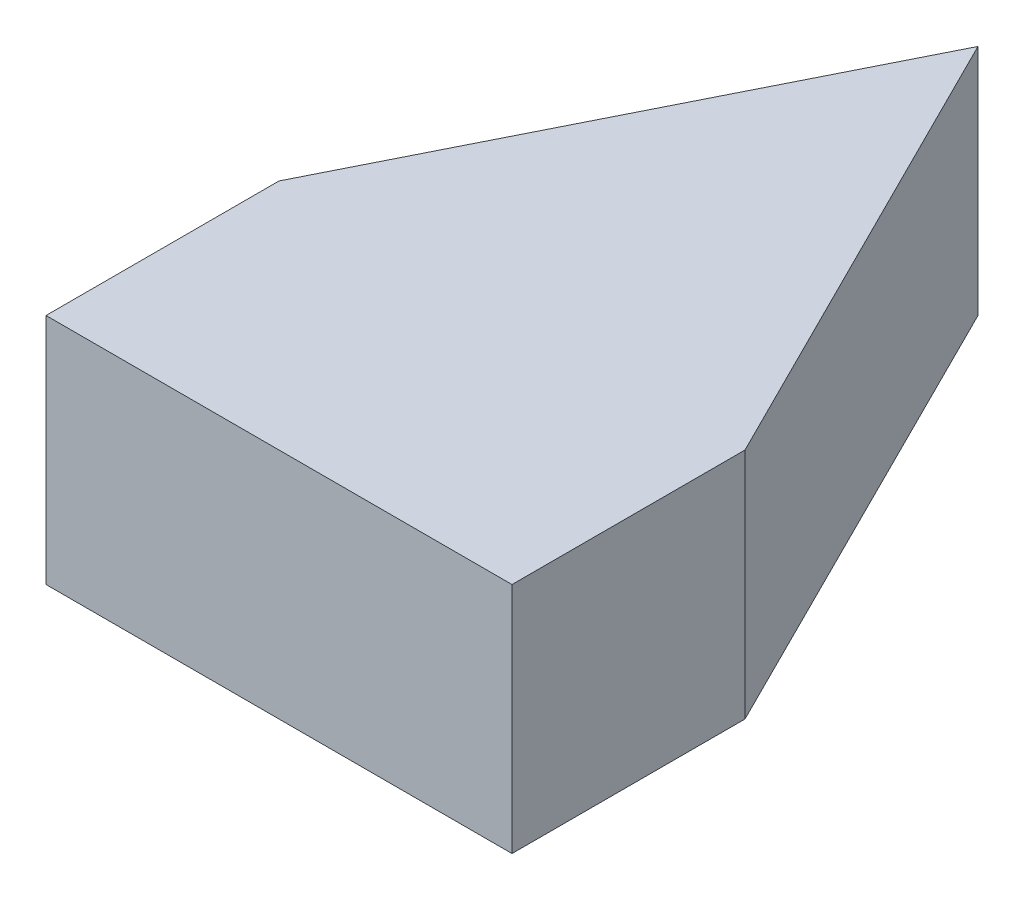
from build123d import *

# Parameters (mm, degrees)
NEEDLE_POINT_DEPTH = 3.175


with BuildPart() as part:
    # Needle Point Sketch → Needle Point (new body)
    with BuildSketch(Plane(origin=(0, 0, 0), x_dir=(1, 0, 0), z_dir=(0, 1, 0))):
        Polygon((6.35, 0), (3.175, 6.35), (0, 0), (0, -3.175), (6.35, -3.175), align=None)
    extrude(amount=NEEDLE_POINT_DEPTH)


solid = part.part
